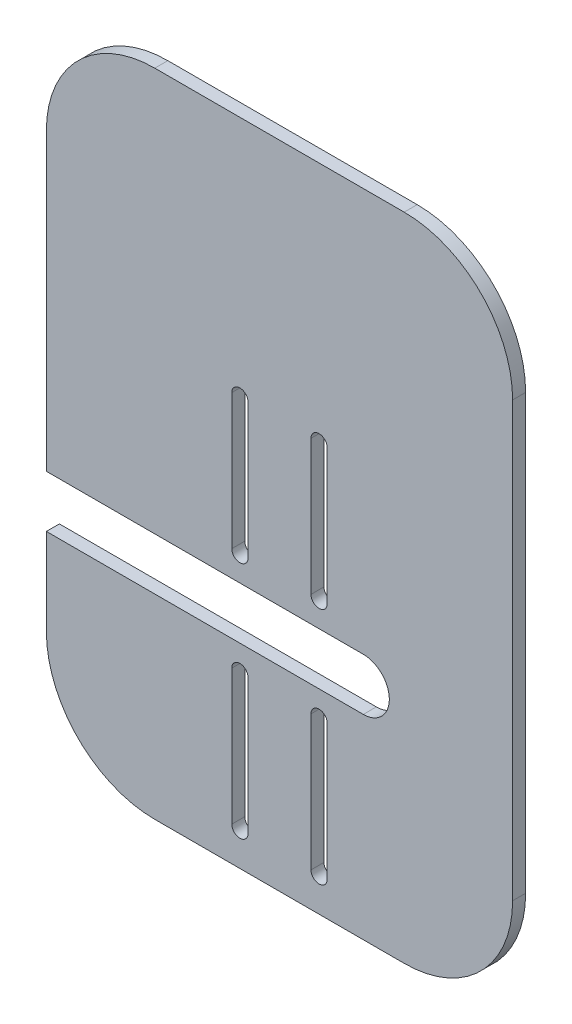
from build123d import *

# Parameters (mm, degrees)
BOSS_EXTRUDE1_DEPTH = 3
CUT_EXTRUDE1_DEPTH  = 10


with BuildPart() as part:
    # Sketch2 → Boss-Extrude1 (new body)
    with BuildSketch(Plane.XY):
        with BuildLine():
            Line((-53.128634422, -19.547588701), (-62.746809975, -19.547588701))
            Line((-62.746809975, -19.547588701), (-126.203620945, -19.547588701))
            Line((-126.203620945, -19.547588701), (-126.203620945, 48.452411299))
            ThreePointArc((-126.203620945, 48.452411299), (-118.881290474, 66.130080829), (-101.203620945, 73.452411299))
            Line((-101.203620945, 73.452411299), (-43.703620945, 73.452411299))
            ThreePointArc((-43.703620945, 73.452411299), (-26.025951415, 66.130080829), (-18.703620945, 48.452411299))
            Line((-18.703620945, 48.452411299), (-18.703620945, -51.547588701))
            ThreePointArc((-18.703620945, -51.547588701), (-26.025951415, -69.225258231), (-43.703620945, -76.547588701))
            Line((-43.703620945, -76.547588701), (-101.203620945, -76.547588701))
            ThreePointArc((-101.203620945, -76.547588701), (-118.881290474, -69.225258231), (-126.203620945, -51.547588701))
            Line((-126.203620945, -51.547588701), (-126.203620945, -31.547588701))
            Line((-126.203620945, -31.547588701), (-62.746809975, -31.547588701))
            Line((-62.746809975, -31.547588701), (-53.128634422, -31.547588701))
            ThreePointArc((-53.128634422, -31.547588701), (-47.128634422, -25.547588701), (-53.128634422, -19.547588701))
        make_face()
    extrude(amount=BOSS_EXTRUDE1_DEPTH)

    # Sketch3 → Cut-Extrude1 (cut)
    with BuildSketch(Plane.XY.offset(3)):
        with BuildLine():
            Line((-61.448620945, -37.476562772), (-61.448620945, -68.6318397))
            ThreePointArc((-61.448620945, -68.6318397), (-63.323620945, -70.5068397), (-65.198620945, -68.6318397))
            Line((-65.198620945, -68.6318397), (-65.198620945, -37.476562772))
            ThreePointArc((-65.198620945, -37.476562772), (-63.323620945, -35.601562772), (-61.448620945, -37.476562772))
        make_face()
        with BuildLine():
            Line((-83.458620945, -37.476562772), (-83.458620945, -68.6318397))
            ThreePointArc((-83.458620945, -68.6318397), (-81.583620945, -70.5068397), (-79.708620945, -68.6318397))
            Line((-79.708620945, -68.6318397), (-79.708620945, -37.476562772))
            ThreePointArc((-79.708620945, -37.476562772), (-81.583620945, -35.601562772), (-83.458620945, -37.476562772))
        make_face()
        with BuildLine():
            Line((-83.458620945, -13.61861463), (-83.458620945, 17.536662297))
            ThreePointArc((-83.458620945, 17.536662297), (-81.583620945, 19.411662297), (-79.708620945, 17.536662297))
            Line((-79.708620945, 17.536662297), (-79.708620945, -13.61861463))
            ThreePointArc((-79.708620945, -13.61861463), (-81.583620945, -15.49361463), (-83.458620945, -13.61861463))
        make_face()
        with BuildLine():
            Line((-61.448620945, -13.61861463), (-61.448620945, 17.536662297))
            ThreePointArc((-61.448620945, 17.536662297), (-63.323620945, 19.411662297), (-65.198620945, 17.536662297))
            Line((-65.198620945, 17.536662297), (-65.198620945, -13.61861463))
            ThreePointArc((-65.198620945, -13.61861463), (-63.323620945, -15.49361463), (-61.448620945, -13.61861463))
        make_face()
    extrude(amount=-CUT_EXTRUDE1_DEPTH, mode=Mode.SUBTRACT)


solid = part.part
